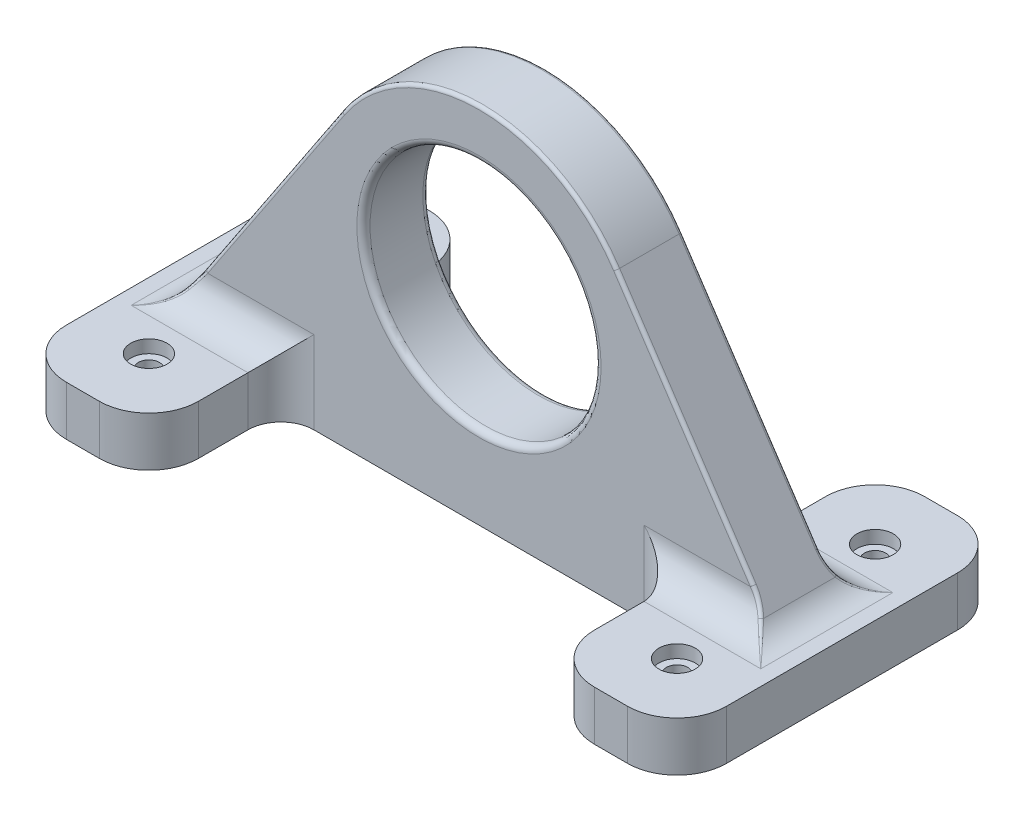
from build123d import *

# Parameters (mm, degrees)
BOSS_EXTRUDE1_DEPTH                           = 10
BOSS_EXTRUDE2_DEPTH                           = 40
CBORE_FOR_M6_CHEESE_SLOTTED_HEAD1_D           = 6.4
CBORE_FOR_M6_CHEESE_SLOTTED_HEAD1_DEPTH       = 15
CBORE_FOR_M6_CHEESE_SLOTTED_HEAD1_CBORE_D     = 11
CBORE_FOR_M6_CHEESE_SLOTTED_HEAD1_CBORE_DEPTH = 3.9
MIRROR4_COPY_1_D                              = 6.4
MIRROR4_COPY_1_DEPTH                          = 15
MIRROR4_COPY_1_CBORE_D                        = 11
MIRROR4_COPY_1_CBORE_DEPTH                    = 3.9
FILLET1_R                                     = 10
FILLET2_R                                     = 15
FILLET3_R                                     = 10
FILLET4_R                                     = 15
FILLET5_R                                     = 1
SKETCH5_R                                     = 35
CUT_EXTRUDE1_DEPTH                            = 61
FILLET6_R                                     = 2


with BuildPart() as part:
    # Sketch1 → Boss-Extrude1 (new body, symmetric)
    with BuildSketch(Plane.XY):
        with BuildLine():
            Line((-100, -60), (100, -60))
            Line((100, -60), (100, -45))
            Line((100, -45), (90.015821042, -45))
            Line((90.015821042, -45), (41.622765631, 27.704609385))
            ThreePointArc((41.622765631, 27.704609385), (0, 50), (-41.622765631, 27.704609385))
            Line((-41.622765631, 27.704609385), (-90.015821042, -45))
            Line((-90.015821042, -45), (-100, -45))
            Line((-100, -45), (-100, -60))
        make_face()
    extrude(amount=BOSS_EXTRUDE1_DEPTH, both=True)

    # Sketch2 → Boss-Extrude2 (add)
    with BuildSketch(Plane.XY.offset(10)):
        Polygon((90.015821042, -45), (60, -45), (60, -60), (100, -60), (100, -45), align=None)
        Polygon((-60, -60), (-60, -45), (-90.015821042, -45), (-100, -45), (-100, -60), align=None)
    boss_extrude2 = extrude(amount=BOSS_EXTRUDE2_DEPTH)

    # Mirror2: Boss-Extrude2 across plane
    add(boss_extrude2.mirror(Plane.XY))

    # CBORE for M6 Cheese Slotted Head1
    with Locations(Plane(origin=(80, -45, -30), x_dir=(0, 0, 1), z_dir=(0, 1, 0))):
        with Locations((0, 0)):
            cbore_for_m6_cheese_slotted_head1 = CounterBoreHole(CBORE_FOR_M6_CHEESE_SLOTTED_HEAD1_D / 2, CBORE_FOR_M6_CHEESE_SLOTTED_HEAD1_CBORE_D / 2, CBORE_FOR_M6_CHEESE_SLOTTED_HEAD1_CBORE_DEPTH, depth=CBORE_FOR_M6_CHEESE_SLOTTED_HEAD1_DEPTH)

    # Mirror3: CBORE for M6 Cheese Slotted Head1 across plane
    add(cbore_for_m6_cheese_slotted_head1.mirror(Plane(origin=(0, 0, 0), x_dir=(0, 0, 1), z_dir=(1, 0, 0))), mode=Mode.SUBTRACT)

    # Mirror4: CBORE for M6 Cheese Slotted Head1 across plane
    add(cbore_for_m6_cheese_slotted_head1.mirror(Plane.XY), mode=Mode.SUBTRACT)

    # Mirror4 copy 1
    with Locations(Plane(origin=(-80, -45, 30), x_dir=(0, 0, -1), z_dir=(0, 1, 0))):
        with Locations((0, 0)):
            CounterBoreHole(MIRROR4_COPY_1_D / 2, MIRROR4_COPY_1_CBORE_D / 2, MIRROR4_COPY_1_CBORE_DEPTH, depth=MIRROR4_COPY_1_DEPTH)

    # Fillet1
    fillet1_edges = [part.edges().sort_by_distance(p)[0] for p in [
        (90.015821042, -45, 0),
        (60, -52.5, 10),
        (75.007910521, -45, 10),
        (75.007910521, -45, -10),
        (60, -52.5, -10),
    ]]
    fillet(fillet1_edges, radius=FILLET1_R)

    # Fillet2
    fillet2_edges = [part.edges().sort_by_distance(p)[0] for p in [
        (60, -52.5, 50),
        (100, -52.5, 50),
        (100, -52.5, -50),
        (60, -52.5, -50),
    ]]
    fillet(fillet2_edges, radius=FILLET2_R)

    # Fillet3
    fillet3_edges = [part.edges().sort_by_distance(p)[0] for p in [
        (-90.015821042, -45, 0),
        (-75.007910521, -45, 10),
        (-60, -52.5, 10),
        (-75.007910521, -45, -10),
        (-60, -52.5, -10),
    ]]
    fillet(fillet3_edges, radius=FILLET3_R)

    # Fillet4
    fillet4_edges = [part.edges().sort_by_distance(p)[0] for p in [
        (-60, -52.5, 50),
        (-100, -52.5, 50),
        (-100, -52.5, -50),
        (-60, -52.5, -50),
    ]]
    fillet(fillet4_edges, radius=FILLET4_R)

    # Fillet5
    fillet5_edges = [part.edges().sort_by_distance(p)[0] for p in [
        (62.491233684, -3.647695307, 10),
        (62.491233684, -3.647695307, -10),
        (85.262771791, -37.85912852, 10.417443759),
        (85.262771791, -37.85912852, -10.417443759),
        (90.886474153, -43.93738446, -15.514115582),
        (90.886474153, -43.93738446, 15.514115582),
        (-85.262771791, -37.85912852, 10.417443759),
        (-85.262771791, -37.85912852, -10.417443759),
        (-90.886474153, -43.93738446, 15.514115582),
        (-90.886474153, -43.93738446, -15.514115582),
        (0, 50, 10),
        (-62.491233684, -3.647695307, 10),
        (-62.491233684, -3.647695307, -10),
        (0, 50, -10),
    ]]
    fillet(fillet5_edges, radius=FILLET5_R)

    # Sketch5 → Cut-Extrude1 (cut, through all)
    with BuildSketch(Plane(origin=(0, 0, -10), x_dir=(-1, 0, 0), z_dir=(0, 0, -1))):
        Circle(SKETCH5_R)
    extrude(amount=-CUT_EXTRUDE1_DEPTH, mode=Mode.SUBTRACT)

    # Fillet6
    fillet6_edges = [part.edges().sort_by_distance(p)[0] for p in [
        (35, 0, 10),
        (35, 0, -10),
    ]]
    fillet(fillet6_edges, radius=FILLET6_R)


solid = part.part
